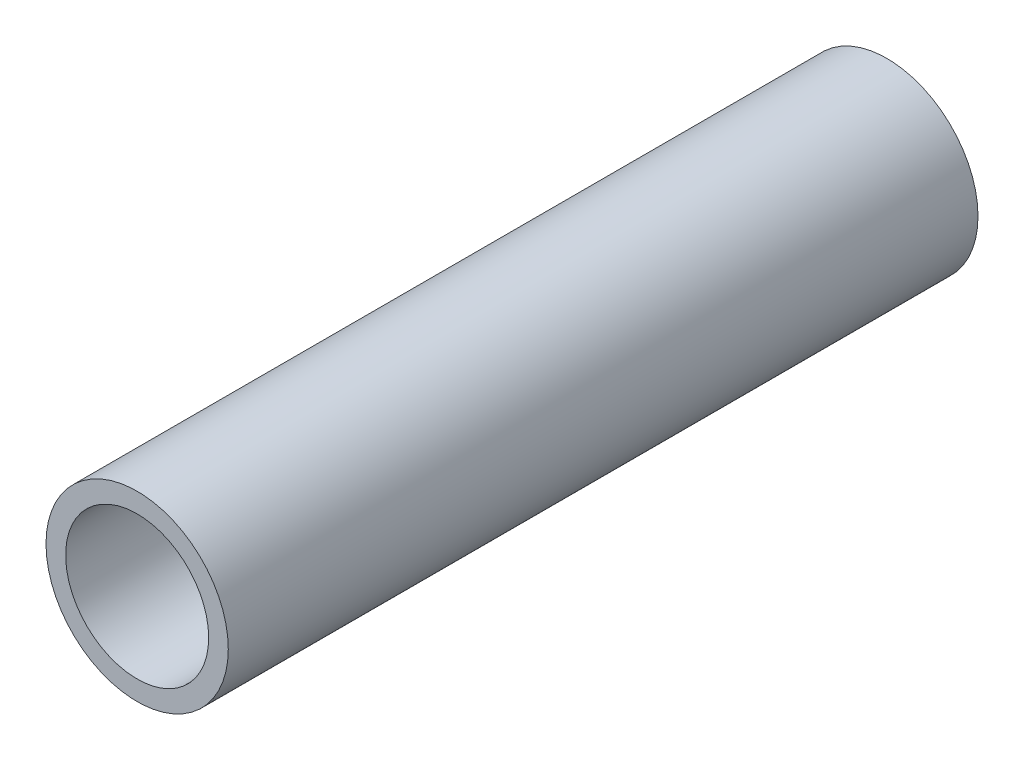
from build123d import *

# Parameters (mm, degrees)
SKETCH3_R                = 13.335
SKETCH3_R_2              = 10.4648
BOSS_EXTRUDE1_DEPTH      = 762
BOSS_EXTRUDE1_DEPTH_BACK = 762
SKETCH4_R                = 13.335
CUT_EXTRUDE2_DEPTH       = 1414.311


with BuildPart() as part:
    # Sketch3 → Boss-Extrude1 (new body, two sides)
    with BuildSketch(Plane.XY) as boss_extrude1_sk:
        Circle(SKETCH3_R)
        Circle(SKETCH3_R_2, mode=Mode.SUBTRACT)
    extrude(amount=BOSS_EXTRUDE1_DEPTH)
    extrude(boss_extrude1_sk.sketch, amount=-BOSS_EXTRUDE1_DEPTH_BACK)

    # Sketch4 → Cut-Extrude2 (cut)
    with BuildSketch(Plane.XY.offset(762)):
        Circle(SKETCH4_R)
    extrude(amount=-CUT_EXTRUDE2_DEPTH, mode=Mode.SUBTRACT)


solid = part.part
